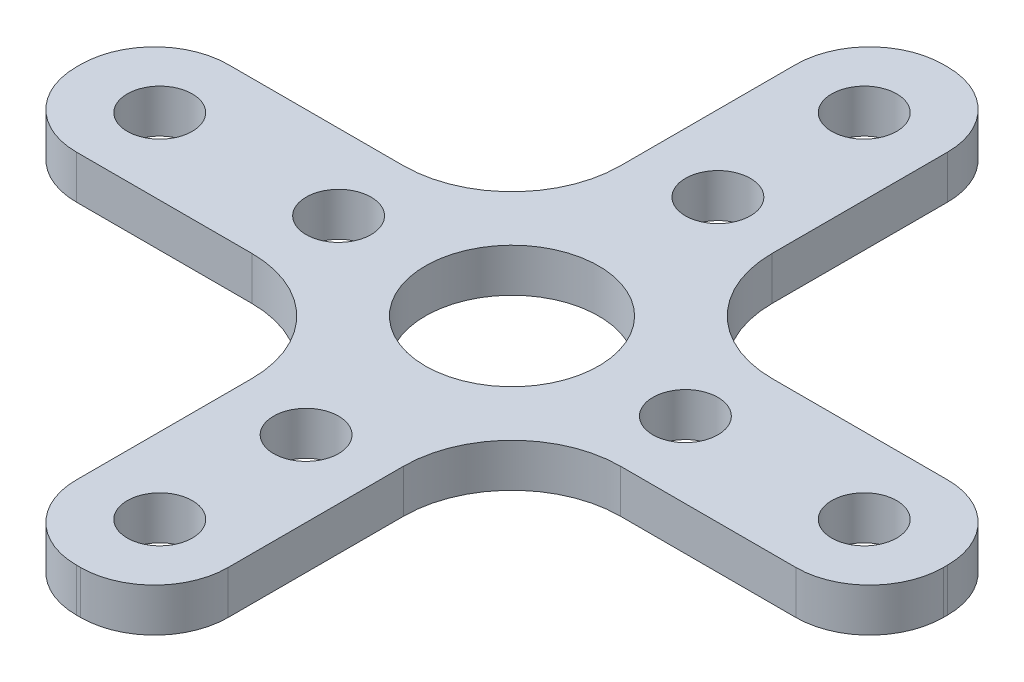
from build123d import *

# Parameters (mm, degrees)
CROQUIS1_R              = 4
CROQUIS1_R_2            = 1.5
SALIENTE_EXTRUIR1_DEPTH = 2


with BuildPart() as part:
    # Croquis1 → Saliente-Extruir1 (new body)
    with BuildSketch(Plane(origin=(0, 0, 0), x_dir=(1, 0, 0), z_dir=(0, 1, 0))):
        with BuildLine():
            Line((16.6, 3.5), (8.5, 3.5))
            ThreePointArc((8.5, 3.5), (4.964466094, 4.964466094), (3.5, 8.5))
            Line((3.5, 8.5), (3.5, 16.6))
            ThreePointArc((3.5, 16.6), (2.504163056, 19.004163056), (0.1, 20))
            Line((0.1, 20), (-0.1, 20))
            ThreePointArc((-0.1, 20), (-2.504163056, 19.004163056), (-3.5, 16.6))
            Line((-3.5, 16.6), (-3.5, 8.5))
            ThreePointArc((-3.5, 8.5), (-4.964466094, 4.964466094), (-8.5, 3.5))
            Line((-8.5, 3.5), (-16.6, 3.5))
            ThreePointArc((-16.6, 3.5), (-19.004163056, 2.504163056), (-20, 0.1))
            Line((-20, 0.1), (-20, -0.1))
            ThreePointArc((-20, -0.1), (-19.004163056, -2.504163056), (-16.6, -3.5))
            Line((-16.6, -3.5), (-8.5, -3.5))
            ThreePointArc((-8.5, -3.5), (-4.964466094, -4.964466094), (-3.5, -8.5))
            Line((-3.5, -8.5), (-3.5, -16.6))
            ThreePointArc((-3.5, -16.6), (-2.504163056, -19.004163056), (-0.1, -20))
            Line((-0.1, -20), (0.1, -20))
            ThreePointArc((0.1, -20), (2.504163056, -19.004163056), (3.5, -16.6))
            Line((3.5, -16.6), (3.5, -8.5))
            ThreePointArc((3.5, -8.5), (4.964466094, -4.964466094), (8.5, -3.5))
            Line((8.5, -3.5), (16.6, -3.5))
            ThreePointArc((16.6, -3.5), (19.004163056, -2.504163056), (20, -0.1))
            Line((20, -0.1), (20, 0.1))
            ThreePointArc((20, 0.1), (19.004163056, 2.504163056), (16.6, 3.5))
        make_face()
        Circle(CROQUIS1_R, mode=Mode.SUBTRACT)
        with Locations((0, 9.5)):
            Circle(CROQUIS1_R_2, mode=Mode.SUBTRACT)
        with Locations((0, 16.25)):
            Circle(CROQUIS1_R_2, mode=Mode.SUBTRACT)
        with Locations((0, -9.5)):
            Circle(CROQUIS1_R_2, mode=Mode.SUBTRACT)
        with Locations((0, -16.25)):
            Circle(CROQUIS1_R_2, mode=Mode.SUBTRACT)
        with Locations((8, 0)):
            Circle(CROQUIS1_R_2, mode=Mode.SUBTRACT)
        with Locations((16.25, 0)):
            Circle(CROQUIS1_R_2, mode=Mode.SUBTRACT)
        with Locations((-16.25, 0)):
            Circle(CROQUIS1_R_2, mode=Mode.SUBTRACT)
        with Locations((-8, 0)):
            Circle(CROQUIS1_R_2, mode=Mode.SUBTRACT)
    extrude(amount=SALIENTE_EXTRUIR1_DEPTH)


solid = part.part
